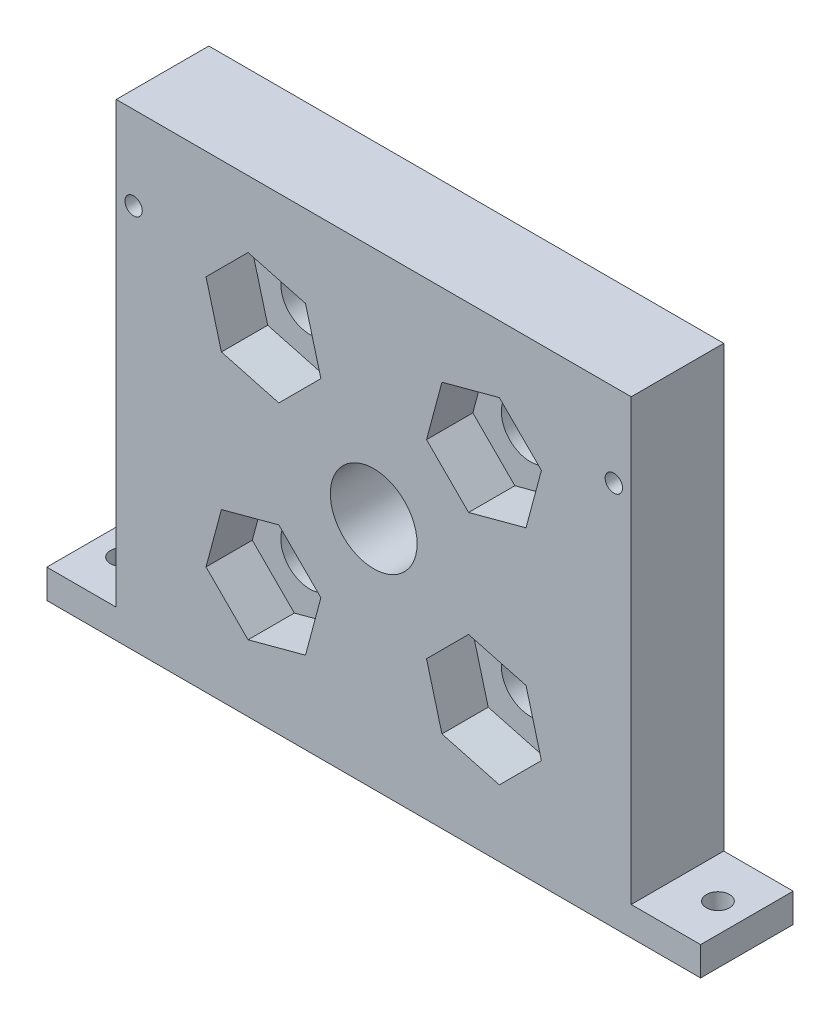
from build123d import *

# Parameters (mm, degrees)
ESQUISSE2_R             = 5
ESQUISSE2_R_2           = 1.5
ESQUISSE2_R_3           = 7.5
BOSS_EXTRU_1_DEPTH      = 16
ESQUISSE4_R             = 2
ENL_V_MAT_EXTRU_1_DEPTH = 6
ENL_V_MAT_EXTRU_2_DEPTH = 8


with BuildPart() as part:
    # Esquisse2 → Boss.-Extru.1 (new body)
    with BuildSketch(Plane.XY):
        Polygon((-56.5, 0), (56.5, 0), (56.5, 5), (44.5, 5), (44.5, 81), (-44.5, 81), (-44.5, 5), (-56.5, 5), align=None)
        with Locations(Location((-19.056527753, 21.443472247, 0), (0, 0, 180))):  # turned: the seam where the file's is
            Circle(ESQUISSE2_R, mode=Mode.SUBTRACT)
        with Locations((-19.056527753, 59.556527753)):
            Circle(ESQUISSE2_R, mode=Mode.SUBTRACT)
        with Locations(Location((19.056527753, 59.556527753, 0), (0, 0, 180))):  # turned: the seam where the file's is
            Circle(ESQUISSE2_R, mode=Mode.SUBTRACT)
        with Locations((19.056527753, 21.443472247)):
            Circle(ESQUISSE2_R, mode=Mode.SUBTRACT)
        with Locations((-41.5, 66.578130392)):
            Circle(ESQUISSE2_R_2, mode=Mode.SUBTRACT)
        with Locations(Location((41.5, 66.578130392, 0), (0, 0, 180))):  # turned: the seam where the file's is
            Circle(ESQUISSE2_R_2, mode=Mode.SUBTRACT)
        with Locations((0, 40.5)):
            Circle(ESQUISSE2_R_3, mode=Mode.SUBTRACT)
    extrude(amount=BOSS_EXTRU_1_DEPTH)

    # Esquisse4 → Enlèv. mat.-Extru.1 (cut, through all)
    with BuildSketch(Plane(origin=(0, 5, 0), x_dir=(1, 0, 0), z_dir=(0, 1, 0))):
        with Locations(Location((-51.5, -8, 0), (0, 0, 180))):  # turned: the seam where the file's is
            Circle(ESQUISSE4_R)
        with Locations((51.5, -8)):
            Circle(ESQUISSE4_R)
    extrude(amount=-ENL_V_MAT_EXTRU_1_DEPTH, mode=Mode.SUBTRACT)

    # Esquisse5 → Enlèv. mat.-Extru.2 (cut)
    with BuildSketch(Plane.XY.offset(16)):
        Polygon((-21.71636832, 69.483187891), (-28.983187891, 62.21636832), (-26.323347323, 52.289708183), (-16.396687186, 49.629867615), (-9.129867615, 56.896687186), (-11.789708183, 66.823347323), align=None)
        Polygon((-21.71636832, 11.516812109), (-28.983187891, 18.78363168), (-26.323347323, 28.710291817), (-16.396687186, 31.370132385), (-9.129867615, 24.103312814), (-11.789708183, 14.176652677), align=None)
        Polygon((26.323347323, 52.289708183), (16.396687186, 49.629867615), (9.129867615, 56.896687186), (11.789708183, 66.823347323), (21.71636832, 69.483187891), (28.983187891, 62.21636832), align=None)
        Polygon((16.396687186, 31.370132385), (9.129867615, 24.103312814), (11.789708183, 14.176652677), (21.71636832, 11.516812109), (28.983187891, 18.78363168), (26.323347323, 28.710291817), align=None)
    extrude(amount=-ENL_V_MAT_EXTRU_2_DEPTH, mode=Mode.SUBTRACT)


solid = part.part
